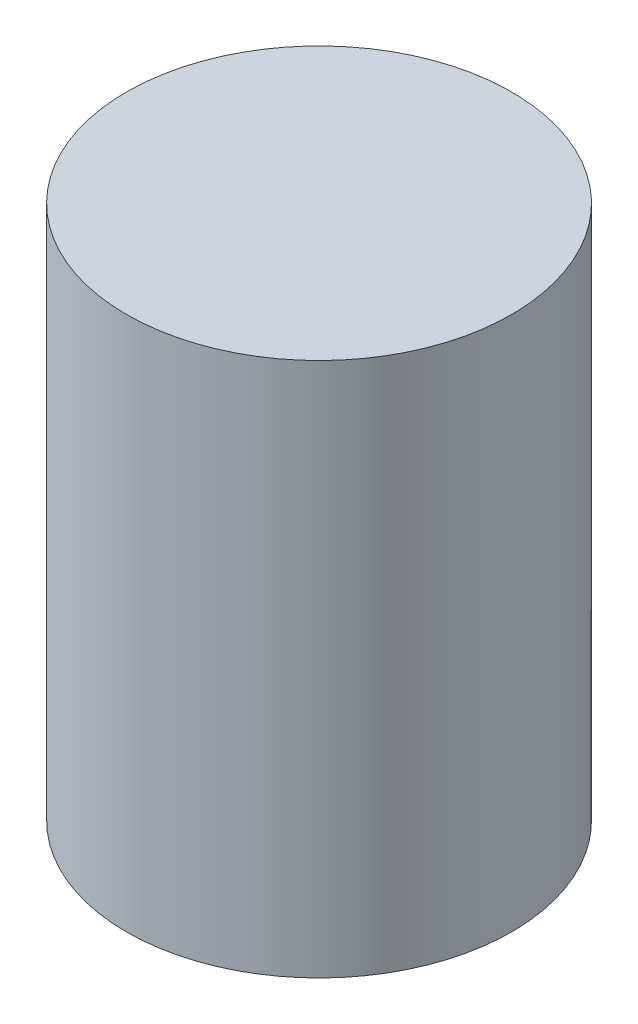
from build123d import *

# Parameters (mm, degrees)
SKETCH1_R           = 9.723
BOSS_EXTRUDE1_DEPTH = 13.49375


with BuildPart() as part:
    # Sketch1 → Boss-Extrude1 (new body, symmetric)
    with BuildSketch(Plane(origin=(0, 0, 0), x_dir=(1, 0, 0), z_dir=(0, 1, 0))):
        Circle(SKETCH1_R)
    extrude(amount=BOSS_EXTRUDE1_DEPTH, both=True)


solid = part.part
